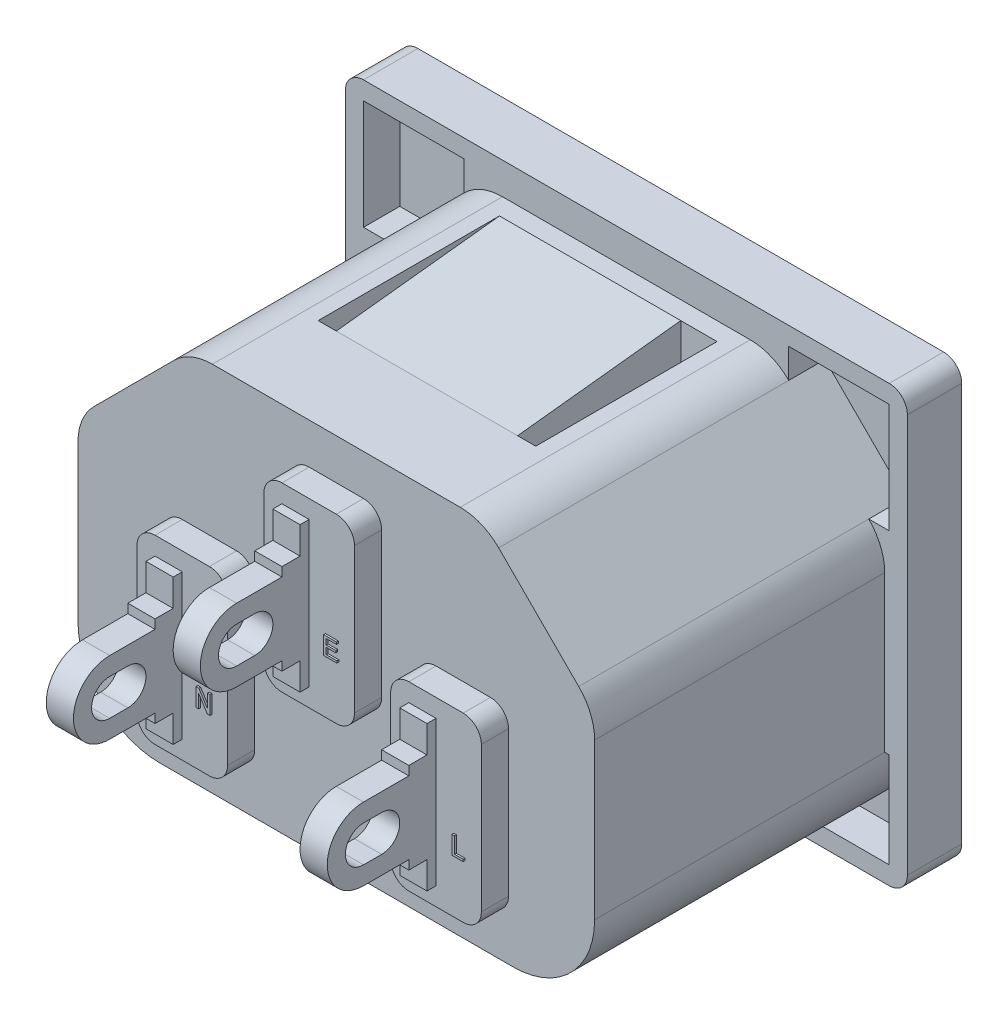
from build123d import *

# Parameters (mm, degrees)
SKETCH_1_W             = 31
SKETCH_1_H             = 24
FEATURE_DEPTH          = 18.3
FEATURE1_DEPTH         = 17
FEATURE2_R             = 2.5
FEATURE3_R             = 1
FEATURE4_T             = -2
FEATURE5_DEPTH         = 2
FEATURE6_DEPTH         = 10
SKETCH_5_W             = 1
SKETCH_5_H             = 2
FEATURE7_DEPTH         = 0.5
SKETCH_7_W             = 5
SKETCH_7_H             = 10
FEATURE8_DEPTH         = 1.5
FEATURE9_R             = 1
FEATURE10_DEPTH        = 2
FEATURE11_DEPTH        = 4
SKETCH_10_W            = 0.5
SKETCH_10_H            = 2
FEATURE12_DEPTH        = 0.5
SKETCH_11_W            = 1.5
SKETCH_11_H            = 8
FEATURE14_DEPTH        = 6
FEATURE14_DEPTH_BACK   = 15.5
FEATURE14_2_DEPTH      = 6
FEATURE14_2_DEPTH_BACK = 15.5
FEATURE14_3_DEPTH      = 6
FEATURE14_3_DEPTH_BACK = 15.5
SKETCH_11_2_W          = 1.5
SKETCH_11_2_H          = 8
FEATURE15_DEPTH        = 29.363709207
SKETCH_13_W            = 12
SKETCH_13_H            = 1
SKETCH_13_H_2          = 3
FEATURE16_DEPTH        = 37.776351097
FEATURE17_SIZE         = 0.5
FEATURE17_SIZE2        = 0.866025404
FEATURE18_DEPTH        = 37.776351097
FEATURE19_SIZE         = 0.5
FEATURE19_SIZE2        = 0.866025404
FEATURE20_DEPTH        = 0.1
SKETCH_16_W            = 12
SKETCH_16_H            = 2.5
SKETCH_16_H_2          = 1.5
FEATURE21_DEPTH        = 33.962099448
FEATURE22_SIZE         = 0.5
FEATURE22_SIZE2        = 0.866025404
FEATURE23_DEPTH        = 1
FEATURE24_DEPTH        = 2


with BuildPart() as part:
    # 草圖1 → Feature (new body)
    with BuildSketch(Plane.XY):
        Rectangle(SKETCH_1_W, SKETCH_1_H)
    extrude(amount=FEATURE_DEPTH)

    # 草圖2 → Feature1 (cut)
    with BuildSketch(Plane(origin=(0, 0, 0), x_dir=(-1, 0, 0), z_dir=(0, 0, -1))):
        Polygon((-7.25, 8.25), (7.25, 8.25), (12.25, 3.25), (12.25, -8.25), (-12.25, -8.25), (-12.25, 3.25), align=None)
    extrude(amount=-FEATURE1_DEPTH, mode=Mode.SUBTRACT)

    # Feature2
    feature2_edges = [part.edges().sort_by_distance(p)[0] for p in [
        (-12.25, -8.25, 8.5),
        (12.25, -8.25, 8.5),
    ]]
    fillet(feature2_edges, radius=FEATURE2_R)

    # Feature3
    feature3_edges = [part.edges().sort_by_distance(p)[0] for p in [
        (12.25, 3.25, 8.5),
        (7.25, 8.25, 8.5),
        (-7.25, 8.25, 8.5),
        (-12.25, 3.25, 8.5),
    ]]
    fillet(feature3_edges, radius=FEATURE3_R)

    # Feature4
    feature4_openings = [part.faces().sort_by_distance(p)[0] for p in [
        (0, 12, 9.15),
        (-15.5, 0, 9.15),
        (15.5, 0, 9.15),
        (0, -12, 9.15),
        (0, 0, 18.3),
    ]]
    offset(amount=FEATURE4_T, openings=feature4_openings, kind=Kind.INTERSECTION)

    # 草圖3 → Feature5 (cut)
    with BuildSketch(Plane(origin=(0, 10.25, 0), x_dir=(1, 0, 0), z_dir=(0, 1, 0))):
        Polygon((-6, -14), (-5, -14), (-5, -5), (5, -5), (5, -14), (6, -14), (6, -4), (-6, -4), align=None)
    extrude(amount=-FEATURE5_DEPTH, mode=Mode.SUBTRACT)

    # 草圖4 → Feature6 (add)
    with BuildSketch(Plane.ZY.offset(5)):
        Polygon((5, 10.25), (5, 11.25), (14, 10.25), align=None)
    extrude(amount=-FEATURE6_DEPTH)

    # 草圖5 → Feature7 (add)
    with BuildSketch(Plane.XZ.offset(-8.25)):
        with Locations((-5.5, 10)):
            Rectangle(SKETCH_5_W, SKETCH_5_H)
        with Locations((5.5, 10)):
            Rectangle(SKETCH_5_W, SKETCH_5_H)
    extrude(amount=-FEATURE7_DEPTH)

    # 草圖7 → Feature8 (add)
    with BuildSketch(Plane.XY.offset(19)):
        with Locations((0, 3)):
            Rectangle(SKETCH_7_W, SKETCH_7_H)
        with Locations((-7, -3)):
            Rectangle(SKETCH_7_W, SKETCH_7_H)
        with Locations((7, -3)):
            Rectangle(SKETCH_7_W, SKETCH_7_H)
    extrude(amount=FEATURE8_DEPTH)

    # Feature9
    feature9_edges = [part.edges().sort_by_distance(p)[0] for p in [
        (-2.5, 8, 19.75),
        (-2.5, -2, 19.75),
        (2.5, -2, 19.75),
        (2.5, 8, 19.75),
        (-9.5, 2, 19.75),
        (-9.5, -8, 19.75),
        (-4.5, -8, 19.75),
        (-4.5, 2, 19.75),
        (4.5, 2, 19.75),
        (4.5, -8, 19.75),
        (9.5, -8, 19.75),
        (9.5, 2, 19.75),
        (-15.5, 12, 1),
        (15.5, 12, 1),
        (15.5, -12, 1),
        (-15.5, -12, 1),
    ]]
    fillet(feature9_edges, radius=FEATURE9_R)

    # 草圖8 → Feature10 (cut)
    with BuildSketch(Plane.XZ.offset(10.25)):
        Polygon((-9, 14), (-9, 5), (-5, 5), (-5, 14), (-4.5, 14), (-4.5, 4), (-9.5, 4), (-9.5, 14), align=None)
    feature10 = extrude(amount=-FEATURE10_DEPTH, mode=Mode.SUBTRACT)

    # 草圖9 → Feature11 (add)
    with BuildSketch(Plane(origin=(-5, 0, 0), x_dir=(0, 0, -1), z_dir=(1, 0, 0))):
        Polygon((-5, -10.25), (-5, -11.25), (-16, -10.25), align=None)
    feature11 = extrude(amount=-FEATURE11_DEPTH)

    # 草圖10 → Feature12 (add)
    with BuildSketch(Plane(origin=(0, -8.25, 0), x_dir=(1, 0, 0), z_dir=(0, 1, 0))):
        with Locations((-9.25, -10)):
            Rectangle(SKETCH_10_W, SKETCH_10_H)
        with Locations((-4.75, -10)):
            Rectangle(SKETCH_10_W, SKETCH_10_H)
    feature12 = extrude(amount=-FEATURE12_DEPTH)

    # Feature13: Feature10, Feature11, Feature12 across plane
    add(feature10.mirror(Plane(origin=(0, 0, 0), x_dir=(0, 0, 1), z_dir=(1, 0, 0))), mode=Mode.SUBTRACT)
    add(feature11.mirror(Plane(origin=(0, 0, 0), x_dir=(0, 0, 1), z_dir=(1, 0, 0))))
    add(feature12.mirror(Plane(origin=(0, 0, 0), x_dir=(0, 0, 1), z_dir=(1, 0, 0))))

    # 草圖11<2> → Feature15 (cut, through all)
    with BuildSketch(Plane.XY.offset(20.5)):
        with Locations((-7.75, -3)):
            Rectangle(SKETCH_11_2_W, SKETCH_11_2_H)
        with Locations((-0.75, 3)):
            Rectangle(SKETCH_11_2_W, SKETCH_11_2_H)
        with Locations((6.25, -3)):
            Rectangle(SKETCH_11_2_W, SKETCH_11_2_H)
    extrude(amount=-FEATURE15_DEPTH, mode=Mode.SUBTRACT)

    # 草圖15 → Feature20 (add)
    with BuildSketch(Plane.XY.offset(20.5)):
        Polygon((-6.134615385, -5), (-6.134615385, -4), (-5.985576923, -4), (-5.506410256, -4.74619391), (-5.506410256, -4), (-5.365384615, -4), (-5.365384615, -5), (-5.514423077, -5), (-5.993589744, -4.25380609), (-5.993589744, -5), align=None)
        Polygon((7.980769231, -5), (7.980769231, -4), (8.121794872, -4), (8.121794872, -4.884615385), (8.596153846, -4.884615385), (8.596153846, -5), align=None)
        Polygon((0.903846154, 1), (0.903846154, 2), (1.608974359, 2), (1.608974359, 1.884615385), (1.044871795, 1.884615385), (1.044871795, 1.576923077), (1.570512821, 1.576923077), (1.570512821, 1.461538462), (1.044871795, 1.461538462), (1.044871795, 1.115384615), (1.634615385, 1.115384615), (1.634615385, 1), align=None)
    extrude(amount=FEATURE20_DEPTH)

    # 草圖19 → Feature23 (add)
    with BuildSketch(Plane.XY.offset(2)):
        with BuildLine():
            Line((-14.5, -12), (14.5, -12))
            ThreePointArc((14.5, -12), (15.207106781, -11.707106781), (15.5, -11))
            Line((15.5, -11), (15.5, 11))
            ThreePointArc((15.5, 11), (15.207106781, 11.707106781), (14.5, 12))
            Line((14.5, 12), (-14.5, 12))
            ThreePointArc((-14.5, 12), (-15.207106781, 11.707106781), (-15.5, 11))
            Line((-15.5, 11), (-15.5, -11))
            ThreePointArc((-15.5, -11), (-15.207106781, -11.707106781), (-14.5, -12))
        make_face()
        with BuildLine():
            Line((-14.25, 2.835786438), (-14.25, -5.75))
            ThreePointArc((-14.25, -5.75), (-12.931980515, -8.931980515), (-9.75, -10.25))
            Line((-9.75, -10.25), (9.75, -10.25))
            ThreePointArc((9.75, -10.25), (12.931980515, -8.931980515), (14.25, -5.75))
            Line((14.25, -5.75), (14.25, 2.835786438))
            ThreePointArc((14.25, 2.835786438), (14.021638598, 3.983836735), (13.371320344, 4.957106781))
            Line((13.371320344, 4.957106781), (8.957106781, 9.371320344))
            ThreePointArc((8.957106781, 9.371320344), (7.983836735, 10.021638598), (6.835786438, 10.25))
            Line((6.835786438, 10.25), (-6.835786438, 10.25))
            ThreePointArc((-6.835786438, 10.25), (-7.983836735, 10.021638598), (-8.957106781, 9.371320344))
            Line((-8.957106781, 9.371320344), (-13.371320344, 4.957106781))
            ThreePointArc((-13.371320344, 4.957106781), (-14.021638598, 3.983836735), (-14.25, 2.835786438))
        make_face(mode=Mode.SUBTRACT)
    extrude(amount=FEATURE23_DEPTH)

    # 草圖18 → Feature24 (cut)
    with BuildSketch(Plane.XY.offset(3)):
        Polygon((8.957106781, 9.371320344), (8.957106781, 11), (14.5, 11), (14.5, 4.957106781), (13.371320344, 4.957106781), align=None)
        Polygon((-8.957106781, 9.371320344), (-8.957106781, 11), (-14.5, 11), (-14.5, 4.957106781), (-13.371320344, 4.957106781), align=None)
        with BuildLine():
            Line((14.25, -5.75), (14.5, -5.75))
            Line((14.5, -5.75), (14.5, -11))
            Line((14.5, -11), (9.75, -11))
            Line((9.75, -11), (9.75, -10.25))
            ThreePointArc((9.75, -10.25), (12.931980515, -8.931980515), (14.25, -5.75))
        make_face()
        with BuildLine():
            Line((-14.25, -5.75), (-14.5, -5.75))
            Line((-14.5, -5.75), (-14.5, -11))
            Line((-14.5, -11), (-9.75, -11))
            Line((-9.75, -11), (-9.75, -10.25))
            ThreePointArc((-9.75, -10.25), (-12.931980515, -8.931980515), (-14.25, -5.75))
        make_face()
    extrude(amount=-FEATURE24_DEPTH, mode=Mode.SUBTRACT)


with BuildPart() as body_2:
    # 草圖11 → Feature14 (new, two sides)
    with BuildSketch(Plane.XY.offset(20.5)) as feature14_sk:
        with Locations((-7.75, -3)):
            Rectangle(SKETCH_11_W, SKETCH_11_H)
    extrude(amount=FEATURE14_DEPTH)
    extrude(feature14_sk.sketch, amount=-FEATURE14_DEPTH_BACK)

    # 草圖13 → Feature16 (cut, through all)
    with BuildSketch(Plane(origin=(-7, 0, 0), x_dir=(0, 0, -1), z_dir=(1, 0, 0))):
        with BuildLine():
            ThreePointArc((-26.5, -3), (-25.914213562, -1.585786438), (-24.5, -1))
            Line((-24.5, -1), (-22, -1))
            Line((-22, -1), (-22, -0.5))
            Line((-22, -0.5), (-21, -0.5))
            Line((-21, -0.5), (-21, 1))
            Line((-21, 1), (-26.5, 1))
            Line((-26.5, 1), (-26.5, -3))
        make_face()
        with Locations((-11, 0.5)):
            Rectangle(SKETCH_13_W, SKETCH_13_H)
        with Locations((-11, -5.5)):
            Rectangle(SKETCH_13_W, SKETCH_13_H_2)
        with BuildLine():
            ThreePointArc((-24.5, -5), (-25.914213562, -4.414213562), (-26.5, -3))
            Line((-26.5, -3), (-26.5, -7))
            Line((-26.5, -7), (-21, -7))
            Line((-21, -7), (-21, -5.5))
            Line((-21, -5.5), (-22, -5.5))
            Line((-22, -5.5), (-22, -5))
            Line((-22, -5), (-24.5, -5))
        make_face()
        with BuildLine():
            Line((-24.5, -4), (-23.5, -4))
            ThreePointArc((-23.5, -4), (-22.5, -3), (-23.5, -2))
            Line((-23.5, -2), (-24.5, -2))
            ThreePointArc((-24.5, -2), (-25.5, -3), (-24.5, -4))
        make_face()
    extrude(amount=-FEATURE16_DEPTH, mode=Mode.SUBTRACT)

    # Feature17
    feature17_edges = [body_2.edges().sort_by_distance(p)[0] for p in [
        (-8.5, -2, 5),
        (-7.75, 0, 5),
        (-7, -2, 5),
        (-7.75, -4, 5),
    ]]
    feature17_side = [body_2.faces().sort_by_distance(p)[0] for p in [
        (-7.75, -2, 5),
    ]]
    chamfer(feature17_edges, length=FEATURE17_SIZE, length2=FEATURE17_SIZE2, reference=feature17_side[0])


with BuildPart() as body_3:
    # 草圖11 → Feature14 2 (new, two sides)
    with BuildSketch(Plane.XY.offset(20.5)) as feature14_2_sk:
        with Locations((-0.75, 3)):
            Rectangle(SKETCH_11_W, SKETCH_11_H)
    extrude(amount=FEATURE14_2_DEPTH)
    extrude(feature14_2_sk.sketch, amount=-FEATURE14_2_DEPTH_BACK)

    # 草圖16 → Feature21 (cut, through all)
    with BuildSketch(Plane(origin=(0, 0, 0), x_dir=(0, 0, -1), z_dir=(1, 0, 0))):
        with BuildLine():
            ThreePointArc((-26.5, 3), (-25.914213562, 4.414213562), (-24.5, 5))
            Line((-24.5, 5), (-22, 5))
            Line((-22, 5), (-22, 5.5))
            Line((-22, 5.5), (-21, 5.5))
            Line((-21, 5.5), (-21, 7))
            Line((-21, 7), (-26.5, 7))
            Line((-26.5, 7), (-26.5, 3))
        make_face()
        with Locations((-11, 5.75)):
            Rectangle(SKETCH_16_W, SKETCH_16_H)
        with Locations((-11, -0.25)):
            Rectangle(SKETCH_16_W, SKETCH_16_H_2)
        with BuildLine():
            ThreePointArc((-24.5, 1), (-25.914213562, 1.585786438), (-26.5, 3))
            Line((-26.5, 3), (-26.5, -1))
            Line((-26.5, -1), (-21, -1))
            Line((-21, -1), (-21, 0.5))
            Line((-21, 0.5), (-22, 0.5))
            Line((-22, 0.5), (-22, 1))
            Line((-22, 1), (-24.5, 1))
        make_face()
        with BuildLine():
            Line((-24.5, 2), (-23.5, 2))
            ThreePointArc((-23.5, 2), (-22.5, 3), (-23.5, 4))
            Line((-23.5, 4), (-24.5, 4))
            ThreePointArc((-24.5, 4), (-25.5, 3), (-24.5, 2))
        make_face()
    extrude(amount=-FEATURE21_DEPTH, mode=Mode.SUBTRACT)

    # Feature22
    feature22_edges = [body_3.edges().sort_by_distance(p)[0] for p in [
        (-1.5, 2.5, 5),
        (-0.75, 4.5, 5),
        (0, 2.5, 5),
        (-0.75, 0.5, 5),
    ]]
    feature22_side = [body_3.faces().sort_by_distance(p)[0] for p in [
        (-0.75, 2.5, 5),
    ]]
    chamfer(feature22_edges, length=FEATURE22_SIZE, length2=FEATURE22_SIZE2, reference=feature22_side[0])


with BuildPart() as body_4:
    # 草圖11 → Feature14 3 (new, two sides)
    with BuildSketch(Plane.XY.offset(20.5)) as feature14_3_sk:
        with Locations((6.25, -3)):
            Rectangle(SKETCH_11_W, SKETCH_11_H)
    extrude(amount=FEATURE14_3_DEPTH)
    extrude(feature14_3_sk.sketch, amount=-FEATURE14_3_DEPTH_BACK)

    # 草圖14 → Feature18 (cut, through all)
    with BuildSketch(Plane(origin=(7, 0, 0), x_dir=(0, 0, -1), z_dir=(1, 0, 0))):
        with BuildLine():
            Line((-21, -0.5), (-21, 1))
            Line((-21, 1), (-26.5, 1))
            Line((-26.5, 1), (-26.5, -3))
            ThreePointArc((-26.5, -3), (-25.914213562, -1.585786438), (-24.5, -1))
            Line((-24.5, -1), (-22, -1))
            Line((-22, -1), (-22, -0.5))
            Line((-22, -0.5), (-21, -0.5))
        make_face()
        with BuildLine():
            Line((-24.5, -2), (-23.5, -2))
            ThreePointArc((-23.5, -2), (-22.5, -3), (-23.5, -4))
            Line((-23.5, -4), (-24.5, -4))
            ThreePointArc((-24.5, -4), (-25.5, -3), (-24.5, -2))
        make_face()
        with BuildLine():
            Line((-26.5, -7), (-21, -7))
            Line((-21, -7), (-21, -5.5))
            Line((-21, -5.5), (-22, -5.5))
            Line((-22, -5.5), (-22, -5))
            Line((-22, -5), (-24.5, -5))
            ThreePointArc((-24.5, -5), (-25.914213562, -4.414213562), (-26.5, -3))
            Line((-26.5, -3), (-26.5, -7))
        make_face()
        Polygon((-5, -7), (-5, -4), (-5.866025404, -4), (-17, -4), (-17, -7), align=None)
        Polygon((-5.866025404, 0), (-5, 0), (-5, 1), (-17, 1), (-17, 0), align=None)
    extrude(amount=-FEATURE18_DEPTH, mode=Mode.SUBTRACT)

    # Feature19
    feature19_edges = [body_4.edges().sort_by_distance(p)[0] for p in [
        (5.5, -2, 5),
        (6.25, 0, 5),
        (7, -2, 5),
        (6.25, -4, 5),
    ]]
    feature19_side = [body_4.faces().sort_by_distance(p)[0] for p in [
        (6.25, -2, 5),
    ]]
    chamfer(feature19_edges, length=FEATURE19_SIZE, length2=FEATURE19_SIZE2, reference=feature19_side[0])


solid = Compound([part.part, body_2.part, body_3.part, body_4.part])
